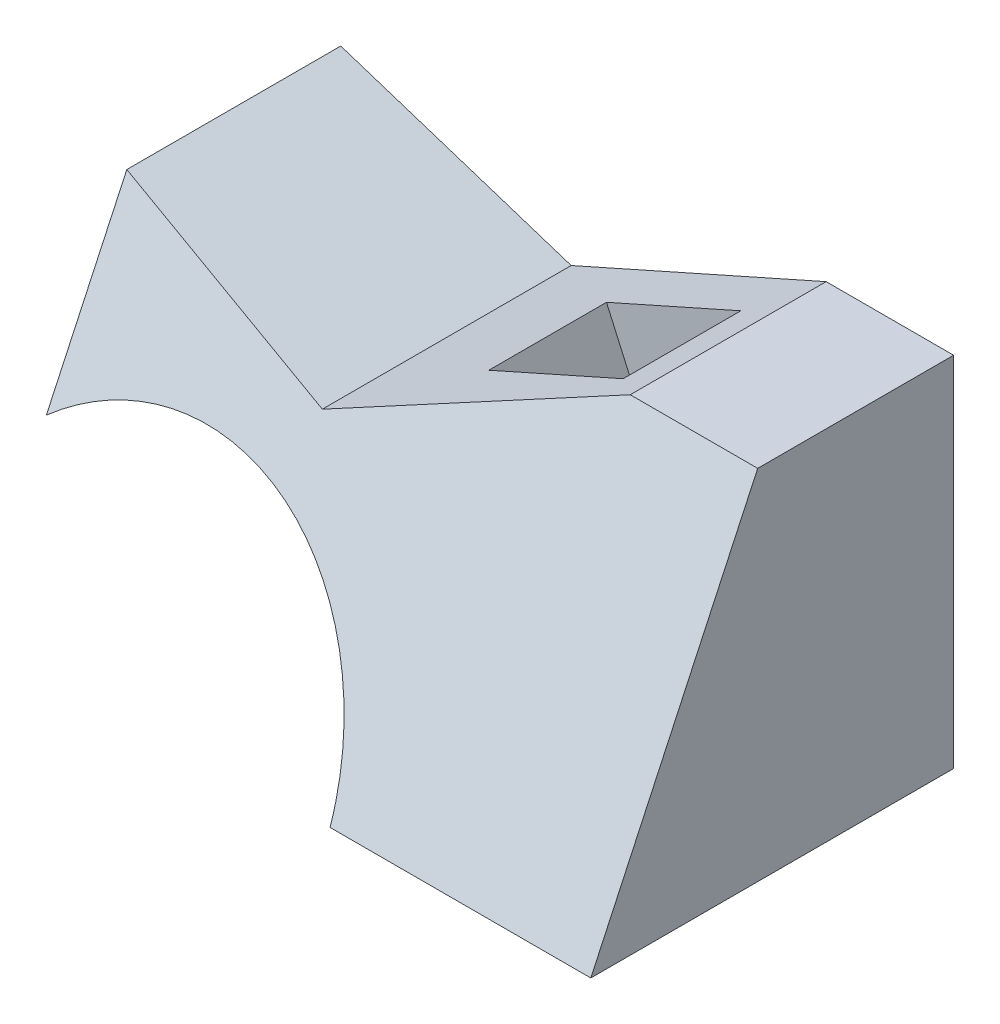
from build123d import *

# Parameters (mm, degrees)
BOSS_EXTRUDE1_DEPTH = 74
CUT_EXTRUDE1_DEPTH  = 126
SKETCH3_W           = 30
SKETCH3_H           = 24
CUT_EXTRUDE2_DEPTH  = 48


with BuildPart() as part:
    # Sketch1 → Boss-Extrude1 (new body)
    with BuildSketch(Plane.XY):
        with BuildLine():
            Line((0, 0), (-53.1821954, 0))
            ThreePointArc((-53.1821954, 0), (-80.068712849, 36.611962713), (-125, 29.941125497))
            Line((-125, 29.941125497), (-125, 65.119334087))
            Line((-125, 65.119334087), (-78, 49.848108364))
            Line((-78, 49.848108364), (-26, 73))
            Line((-26, 73), (0, 73))
            Line((0, 73), (0, 0))
        make_face()
    extrude(amount=BOSS_EXTRUDE1_DEPTH)

    # Sketch2 → Cut-Extrude1 (cut, through all)
    with BuildSketch(Plane(origin=(0, 0, 0), x_dir=(0, 0, -1), z_dir=(1, 0, 0))):
        Polygon((-74, 0), (-39.959540955, 73), (-74, 73), align=None)
    extrude(amount=-CUT_EXTRUDE1_DEPTH, mode=Mode.SUBTRACT)

    # Sketch3 → Cut-Extrude2 (cut)
    with BuildSketch(Plane(origin=(-31.426088247, 70.584149863, 0), x_dir=(0.913545458, 0.406736643, 0), z_dir=(-0.406736643, 0.913545458, 0))):
        with Locations((-16.060406954, -23)):
            Rectangle(SKETCH3_W, SKETCH3_H)
    extrude(amount=-CUT_EXTRUDE2_DEPTH, mode=Mode.SUBTRACT)


solid = part.part
